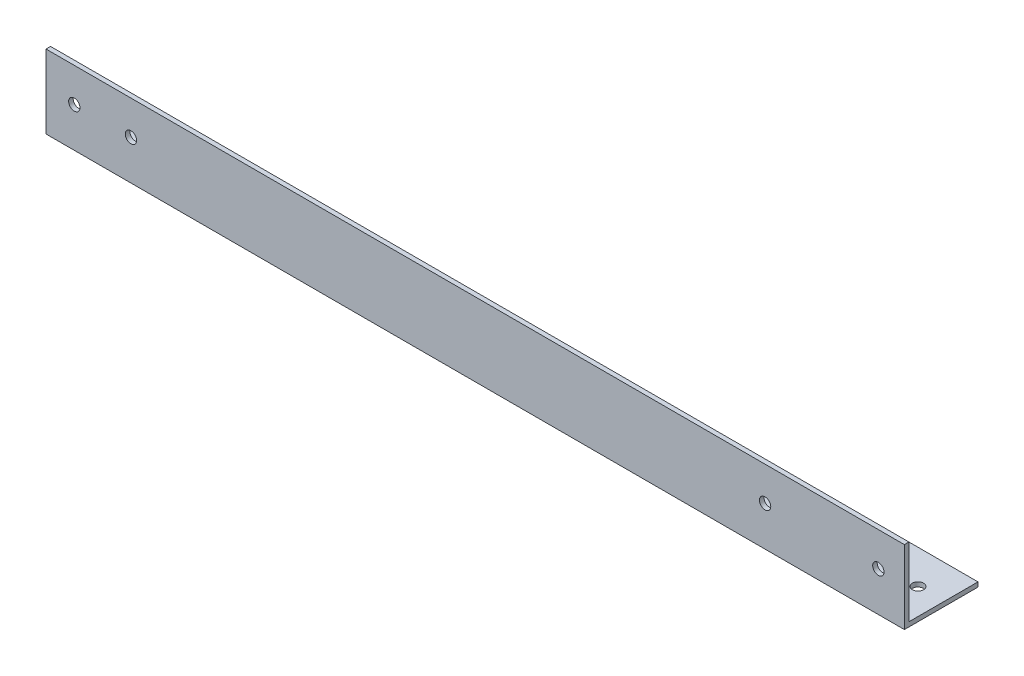
from build123d import *

# Parameters (mm, degrees)
EXTRUDE_1_DEPTH     = 758
SKETCH_2_R          = 5
CUT_EXTRUDE_1_DEPTH = 10
SKETCH_3_R          = 5
CUT_EXTRUDE_2_DEPTH = 10


with BuildPart() as part:
    # Эскиз1 → Вытянуть-Тонкостенный1 (new body)
    with BuildSketch(Plane(origin=(0, 0, 0), x_dir=(0, 0, -1), z_dir=(1, 0, 0))):
        Polygon((65, 0), (0, 0), (0, 65), (4, 65), (4, 4), (65, 4), align=None)
    extrude(amount=EXTRUDE_1_DEPTH)

    # Эскиз2 → Вырез-Вытянуть1 (cut)
    with BuildSketch(Plane.XY):
        with Locations((25, 35)):
            Circle(SKETCH_2_R)
        with Locations((75, 35)):
            Circle(SKETCH_2_R)
        with Locations((735, 35)):
            Circle(SKETCH_2_R)
        with Locations((635, 35)):
            Circle(SKETCH_2_R)
    extrude(amount=-CUT_EXTRUDE_1_DEPTH, mode=Mode.SUBTRACT)

    # Эскиз3 → Вырез-Вытянуть2 (cut)
    with BuildSketch(Plane.XZ):
        with Locations((25, -35)):
            Circle(SKETCH_3_R)
        with Locations((75, -35)):
            Circle(SKETCH_3_R)
        with Locations((735, -35)):
            Circle(SKETCH_3_R)
        with Locations((635, -35)):
            Circle(SKETCH_3_R)
    extrude(amount=-CUT_EXTRUDE_2_DEPTH, mode=Mode.SUBTRACT)


solid = part.part
